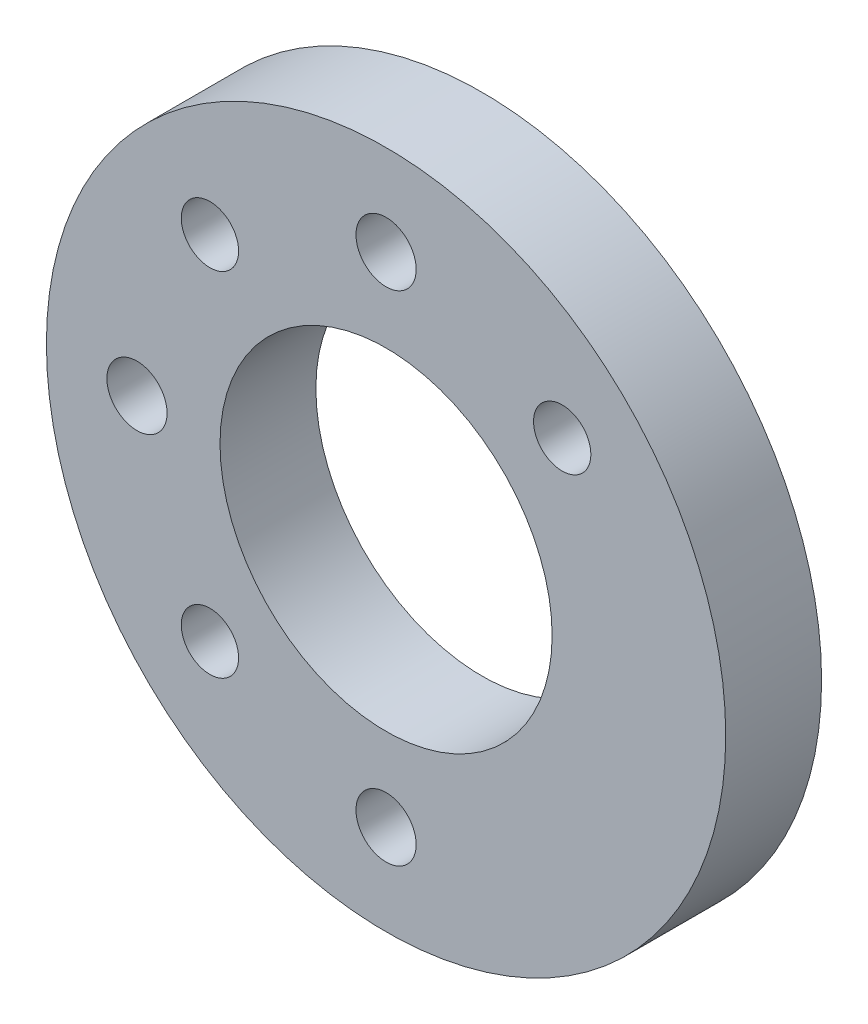
from build123d import *

# Parameters (mm, degrees)
SKETCH1_R             = 22.5
SKETCH1_R_2           = 11
SKETCH1_R_3           = 1.9939
SKETCH1_R_4           = 1.89865
BOSS_EXTRUDE1_DEPTH   = 6.35
CHAMFER1_SIZE         = 2.301024407
CHAMFER1_SIZE2        = 2.00025
CHAMFER1_PART_2_SIZE  = 2.301024407
CHAMFER1_PART_2_SIZE2 = 2.00025
CHAMFER1_PART_3_SIZE  = 2.301024407
CHAMFER1_PART_3_SIZE2 = 2.00025


with BuildPart() as part:
    # Sketch1 → Boss-Extrude1 (new body)
    with BuildSketch(Plane.XY):
        Circle(SKETCH1_R)
        Circle(SKETCH1_R_2, mode=Mode.SUBTRACT)
        with Locations((0, 16.5)):
            Circle(SKETCH1_R_3, mode=Mode.SUBTRACT)
        with Locations((11.66726189, 11.66726189)):
            Circle(SKETCH1_R_4, mode=Mode.SUBTRACT)
        with Locations((0, -16.5)):
            Circle(SKETCH1_R_3, mode=Mode.SUBTRACT)
        with Locations((-11.66726189, -11.66726189)):
            Circle(SKETCH1_R_4, mode=Mode.SUBTRACT)
        with Locations((-16.5, 0)):
            Circle(SKETCH1_R_3, mode=Mode.SUBTRACT)
        with Locations((-11.66726189, 11.66726189)):
            Circle(SKETCH1_R_4, mode=Mode.SUBTRACT)
    extrude(amount=BOSS_EXTRUDE1_DEPTH)

    # Chamfer1
    chamfer1_edges = [part.edges().sort_by_distance(p)[0] for p in [
        (9.76861189, 11.66726189, 0),
    ]]
    chamfer1_side = [part.faces().sort_by_distance(p)[0] for p in [
        (9.76861189, 11.66726189, 3.175),
    ]]
    chamfer(chamfer1_edges, length=CHAMFER1_SIZE, length2=CHAMFER1_SIZE2, reference=chamfer1_side[0])

    # Chamfer1 part 2
    chamfer1_part_2_edges = [part.edges().sort_by_distance(p)[0] for p in [
        (-13.56591189, -11.66726189, 0),
    ]]
    chamfer1_part_2_side = [part.faces().sort_by_distance(p)[0] for p in [
        (-13.56591189, -11.66726189, 3.175),
    ]]
    chamfer(chamfer1_part_2_edges, length=CHAMFER1_PART_2_SIZE, length2=CHAMFER1_PART_2_SIZE2, reference=chamfer1_part_2_side[0])

    # Chamfer1 part 3
    chamfer1_part_3_edges = [part.edges().sort_by_distance(p)[0] for p in [
        (-13.56591189, 11.66726189, 0),
    ]]
    chamfer1_part_3_side = [part.faces().sort_by_distance(p)[0] for p in [
        (-13.56591189, 11.66726189, 3.175),
    ]]
    chamfer(chamfer1_part_3_edges, length=CHAMFER1_PART_3_SIZE, length2=CHAMFER1_PART_3_SIZE2, reference=chamfer1_part_3_side[0])


solid = part.part
